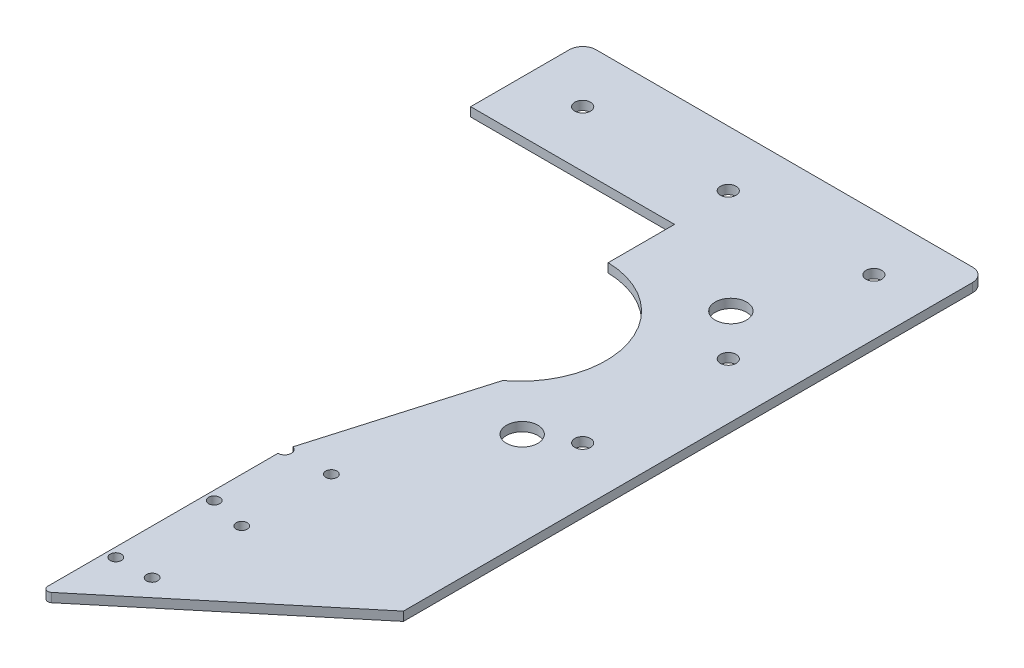
from build123d import *

# Parameters (mm, degrees)
SKETCH_1_R               = 1.75
EXTRUDE_1_DEPTH          = 2
SKETCH_4_W               = 29
SKETCH_4_H               = 65
SKETCH_4_R               = 3.5
EXTRUDE_2_DEPTH          = 2
SKETCH_5_R               = 19.2
CUT_EXTRUDE_1_DEPTH      = 1
CUT_EXTRUDE_1_DEPTH_BACK = 3
CUT_EXTRUDE_2_DEPTH      = 1
CUT_EXTRUDE_2_DEPTH_BACK = 3
FILLET_1_R               = 3
SKETCH_9_R               = 1.5
CUT_EXTRUDE_4_DEPTH      = 1
CUT_EXTRUDE_4_DEPTH_BACK = 3
FILLET_2_R               = 1
SKETCH_13_R              = 1.25
CUT_EXTRUDE_6_DEPTH      = 1
CUT_EXTRUDE_6_DEPTH_BACK = 3
SKETCH_15_R              = 1.25
CUT_EXTRUDE_7_DEPTH      = 1
CUT_EXTRUDE_7_DEPTH_BACK = 3


with BuildPart() as part:
    # Эскиз1 → Бобышка-Вытянуть1 (new body)
    with BuildSketch(Plane(origin=(0, 0, 0), x_dir=(1, 0, 0), z_dir=(0, 1, 0))):
        Polygon((-57.045428332, 34.194915254), (32.954571668, 34.194915254), (32.954571668, -95.805084746), (-11.545428332, -132.805084746), (-11.545428332, -55.805084746), (17.454571668, -55.805084746), (17.454571668, 9.194915254), (-57.045428332, 9.194915254), align=None)
        with Locations((-44.545428332, 21.694915254)):
            Circle(SKETCH_1_R, mode=Mode.SUBTRACT)
        with Locations((-12.045428332, 21.694915254)):
            Circle(SKETCH_1_R, mode=Mode.SUBTRACT)
        with Locations((20.454571668, 21.694915254)):
            Circle(SKETCH_1_R, mode=Mode.SUBTRACT)
        with Locations((20.454571668, -10.805084746)):
            Circle(SKETCH_1_R, mode=Mode.SUBTRACT)
        with Locations((20.454571668, -43.305084746)):
            Circle(SKETCH_1_R, mode=Mode.SUBTRACT)
    extrude(amount=EXTRUDE_1_DEPTH)

    # Эскиз4 → Бобышка-Вытянуть2 (add)
    with BuildSketch(Plane(origin=(0, 2, 0), x_dir=(1, 0, 0), z_dir=(0, 1, 0))):
        with Locations((2.954571668, -23.305084746)):
            Rectangle(SKETCH_4_W, SKETCH_4_H)
        with Locations((12.027100485, -48.375084746)):
            Circle(SKETCH_4_R, mode=Mode.SUBTRACT)
        with Locations((11.493153901, -1.266502513)):
            Circle(SKETCH_4_R, mode=Mode.SUBTRACT)
    extrude(amount=-EXTRUDE_2_DEPTH)

    # Эскиз5 → Вырез-Вытянуть1 (cut, two sides)
    with BuildSketch(Plane(origin=(0, 2, 0), x_dir=(1, 0, 0), z_dir=(0, 1, 0))) as cut_extrude_1_sk:
        with Locations((-12.045428332, -24.805084746)):
            Circle(SKETCH_5_R)
    extrude(amount=CUT_EXTRUDE_1_DEPTH, mode=Mode.SUBTRACT)
    extrude(cut_extrude_1_sk.sketch, amount=-CUT_EXTRUDE_1_DEPTH_BACK, mode=Mode.SUBTRACT)

    # Эскиз7 → Вырез-Вытянуть2 (cut, two sides)
    with BuildSketch(Plane(origin=(0, 2, 0), x_dir=(1, 0, 0), z_dir=(0, 1, 0))) as cut_extrude_2_sk:
        with BuildLine():
            Line((-0.545428332, -40.180064421), (-11.545428332, -77.80926144))
            Line((-11.545428332, -77.80926144), (-11.545428332, -43.998573225))
            ThreePointArc((-11.545428332, -43.998573225), (-5.751853603, -42.935021213), (-0.545428332, -40.180064421))
        make_face()
    extrude(amount=CUT_EXTRUDE_2_DEPTH, mode=Mode.SUBTRACT)
    extrude(cut_extrude_2_sk.sketch, amount=-CUT_EXTRUDE_2_DEPTH_BACK, mode=Mode.SUBTRACT)

    # Скругление1
    fillet_1_edges = [part.edges().sort_by_distance(p)[0] for p in [
        (-57.045428332, 1, -34.194915254),
        (32.954571668, 1, -34.194915254),
    ]]
    fillet(fillet_1_edges, radius=FILLET_1_R)

    # Эскиз9 → Вырез-Вытянуть4 (cut, two sides)
    with BuildSketch(Plane(origin=(0, 2, 0), x_dir=(1, 0, 0), z_dir=(0, 1, 0))) as cut_extrude_4_sk:
        with Locations((-11.545428332, -77.80926144)):
            Circle(SKETCH_9_R)
    extrude(amount=CUT_EXTRUDE_4_DEPTH, mode=Mode.SUBTRACT)
    extrude(cut_extrude_4_sk.sketch, amount=-CUT_EXTRUDE_4_DEPTH_BACK, mode=Mode.SUBTRACT)

    # Скругление2
    fillet_2_edges = [part.edges().sort_by_distance(p)[0] for p in [
        (-11.545428332, 1, 132.805084746),
    ]]
    fillet(fillet_2_edges, radius=FILLET_2_R)

    # Эскиз13 → Вырез-Вытянуть6 (cut, two sides)
    with BuildSketch(Plane(origin=(0, 2, 0), x_dir=(1, 0, 0), z_dir=(0, 1, 0))) as cut_extrude_6_sk:
        with Locations((-9.54492596, -95.551225642)):
            Circle(SKETCH_13_R)
        with Locations((-9.54492596, -117.508337259)):
            Circle(SKETCH_13_R)
    extrude(amount=CUT_EXTRUDE_6_DEPTH, mode=Mode.SUBTRACT)
    extrude(cut_extrude_6_sk.sketch, amount=-CUT_EXTRUDE_6_DEPTH_BACK, mode=Mode.SUBTRACT)

    # Эскиз15 → Вырез-Вытянуть7 (cut, two sides)
    with BuildSketch(Plane(origin=(0, 2, 0), x_dir=(1, 0, 0), z_dir=(0, 1, 0))) as cut_extrude_7_sk:
        with Locations((-1.545428332, -117.398618322)):
            Circle(SKETCH_15_R)
        with Locations((-1.545428332, -97.398618322)):
            Circle(SKETCH_15_R)
        with Locations((-1.545428332, -77.398618322)):
            Circle(SKETCH_15_R)
    extrude(amount=CUT_EXTRUDE_7_DEPTH, mode=Mode.SUBTRACT)
    extrude(cut_extrude_7_sk.sketch, amount=-CUT_EXTRUDE_7_DEPTH_BACK, mode=Mode.SUBTRACT)


solid = part.part
